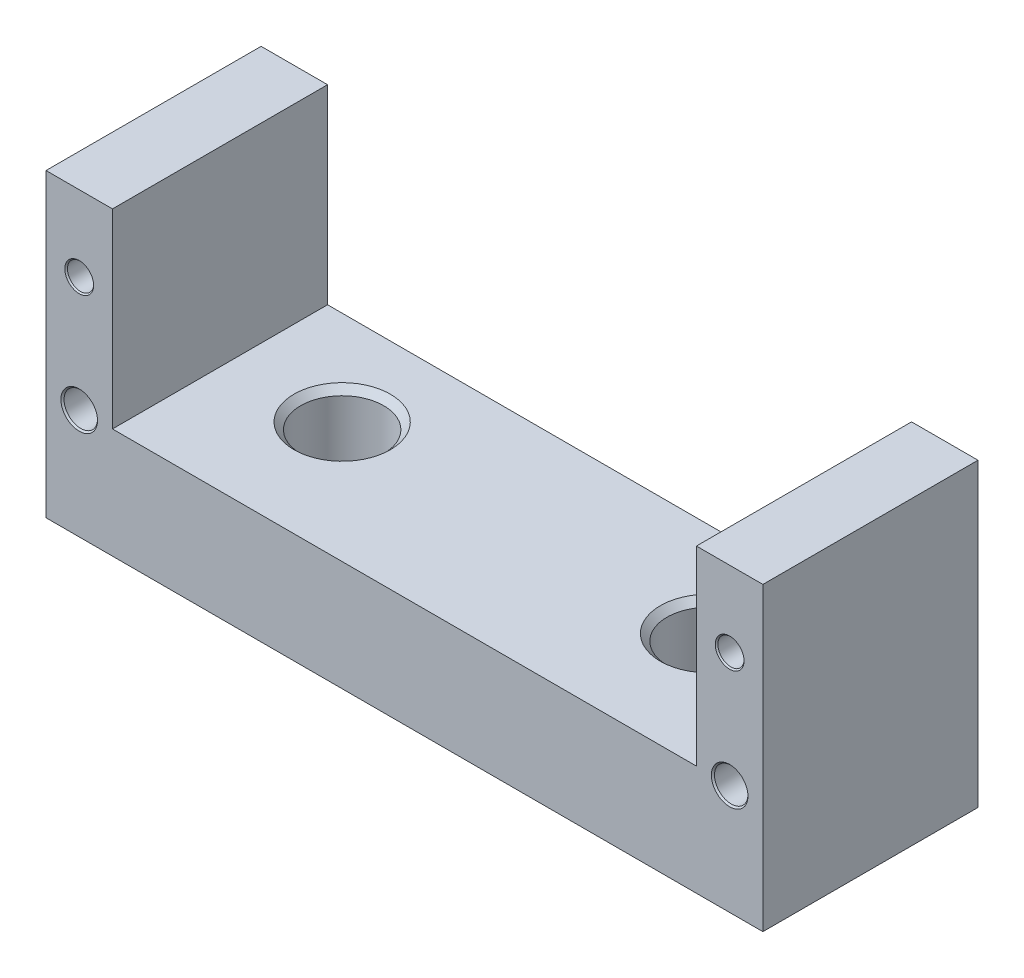
from build123d import *

# Parameters (mm, degrees)
SKETCH1_W                                = 68.4872
SKETCH1_H                                = 20.55
BOSS_EXTRUDE1_DEPTH                      = 28.732
SKETCH2_W                                = 55.7872
SKETCH2_H                                = 18.207
CUT_EXTRUDE1_DEPTH                       = 21.55
F_2_5_2_5_DIAMETER_HOLE1_AT_2_COUNT      = 2
F_2_5_2_5_DIAMETER_HOLE1_AT_2_PITCH      = 62.1372
F_3_2_3_2_DIAMETER_HOLE1_AT_2_COUNT      = 2
F_3_2_3_2_DIAMETER_HOLE1_AT_2_PITCH      = 62.1372
F_5_16_0_3125_DIAMETER_HOLE1_D           = 7.9375
F_5_16_0_3125_DIAMETER_HOLE1_CSINK_D     = 9.2075
F_5_16_0_3125_DIAMETER_HOLE1_CSINK_ANGLE = 90
F_1_8_0_125_DIAMETER_HOLE1_D             = 3.175
F_1_8_0_125_DIAMETER_HOLE1_DEPTH         = 9.53
F_1_8_0_125_DIAMETER_HOLE1_CSINK_D       = 3.81
F_1_8_0_125_DIAMETER_HOLE1_CSINK_ANGLE   = 90
F_1_8_0_125_DIAMETER_HOLE1_TIP           = 0.953866233


with BuildPart() as part:
    # Sketch1 → Boss-Extrude1 (new body)
    with BuildSketch(Plane(origin=(0, 0, 0), x_dir=(1, 0, 0), z_dir=(0, 1, 0))):
        with Locations((0, 10.275)):
            Rectangle(SKETCH1_W, SKETCH1_H)
    extrude(amount=BOSS_EXTRUDE1_DEPTH)

    # Sketch2 → Cut-Extrude1 (cut, through all)
    with BuildSketch(Plane.XY):
        with Locations((0, 19.6285)):
            Rectangle(SKETCH2_W, SKETCH2_H)
    extrude(amount=-CUT_EXTRUDE1_DEPTH, mode=Mode.SUBTRACT)

    # Sketch5 → Ø2.5 (2.5) Diameter Hole1 (revolve, cut)
    with BuildSketch(Plane(origin=(-31.0686, 21.5, 0), x_dir=(0, -1, 0), z_dir=(1, 0, 0))):
        Polygon((0, 0), (0, 20.55), (1.375, 20.55), (1.25, 20.425), (1.25, 0.125), (1.375, 0), align=None)
    f_2_5_2_5_diameter_hole1 = revolve(axis=Axis((-31.0686, 21.5, 6.35), (0, 0, -1)), mode=Mode.SUBTRACT)

    # Ø2.5 (2.5) Diameter Hole1 at 2: Ø2.5 (2.5) Diameter Hole1 ×2
    with Locations(*[(i * F_2_5_2_5_DIAMETER_HOLE1_AT_2_PITCH, 0, 0) for i in range(1, F_2_5_2_5_DIAMETER_HOLE1_AT_2_COUNT)]):
        add(f_2_5_2_5_diameter_hole1, mode=Mode.SUBTRACT)

    # Sketch8 → Ø3.2 (3.2) Diameter Hole1 (revolve, cut)
    with BuildSketch(Plane(origin=(-31.0686, 10.5, 0), x_dir=(0, -1, 0), z_dir=(1, 0, 0))):
        Polygon((0, 0), (0, 20.55), (1.75, 20.55), (1.6, 20.4), (1.6, 0.15), (1.75, 0), align=None)
    f_3_2_3_2_diameter_hole1 = revolve(axis=Axis((-31.0686, 10.5, 6.35), (0, 0, -1)), mode=Mode.SUBTRACT)

    # Ø3.2 (3.2) Diameter Hole1 at 2: Ø3.2 (3.2) Diameter Hole1 ×2
    with Locations(*[(i * F_3_2_3_2_DIAMETER_HOLE1_AT_2_PITCH, 0, 0) for i in range(1, F_3_2_3_2_DIAMETER_HOLE1_AT_2_COUNT)]):
        add(f_3_2_3_2_diameter_hole1, mode=Mode.SUBTRACT)

    # 5/16 (0.3125) Diameter Hole1 (through all)
    with Locations(Plane(origin=(0, 10.525, 0), x_dir=(-1, 0, 0), z_dir=(0, 1, 0))):
        with Locations((17.5, -11.55), (-17.5, -11.55)):
            CounterSinkHole(F_5_16_0_3125_DIAMETER_HOLE1_D / 2, F_5_16_0_3125_DIAMETER_HOLE1_CSINK_D / 2, counter_sink_angle=F_5_16_0_3125_DIAMETER_HOLE1_CSINK_ANGLE)

    # 1/8 (0.125) Diameter Hole1
    with Locations(Plane.XZ):
        with Locations((27.5, -11.55), (-27.5, -11.55)):
            CounterSinkHole(F_1_8_0_125_DIAMETER_HOLE1_D / 2, F_1_8_0_125_DIAMETER_HOLE1_CSINK_D / 2, depth=F_1_8_0_125_DIAMETER_HOLE1_DEPTH, counter_sink_angle=F_1_8_0_125_DIAMETER_HOLE1_CSINK_ANGLE)
            with Locations((0, 0, -(F_1_8_0_125_DIAMETER_HOLE1_DEPTH + F_1_8_0_125_DIAMETER_HOLE1_TIP / 2))):  # 118° drill point
                Cone(0, F_1_8_0_125_DIAMETER_HOLE1_D / 2, F_1_8_0_125_DIAMETER_HOLE1_TIP, mode=Mode.SUBTRACT)


solid = part.part
